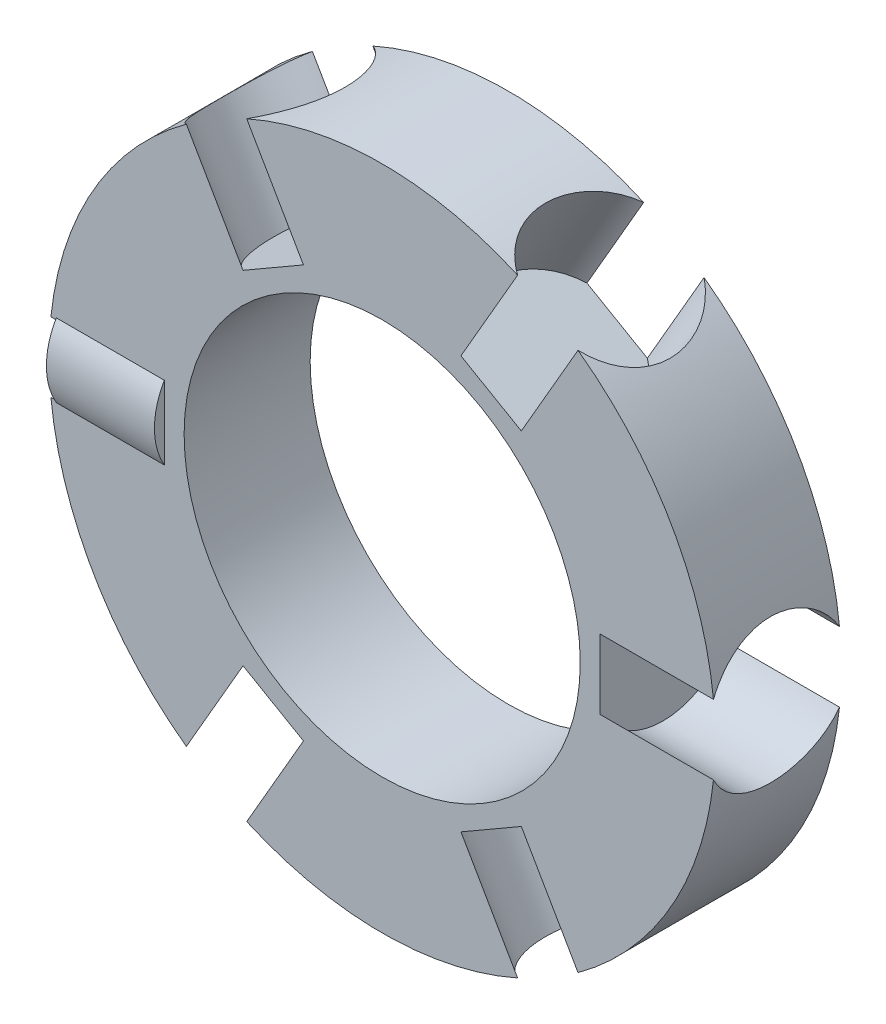
from build123d import *

# Parameters (mm, degrees)
SKETCH1_R           = 18.5
SKETCH1_R_2         = 11
BOSS_EXTRUDE1_DEPTH = 3.5
SKETCH2_R           = 4
CUT_EXTRUDE3_DEPTH  = 6.4
CIRPATTERN1_COUNT   = 6
SKETCH3_R           = 4.05
BOSS_EXTRUDE2_DEPTH = 6


with BuildPart() as part:
    # Sketch1 → Boss-Extrude1 (new, symmetric)
    with BuildSketch(Plane.XY):
        Circle(SKETCH1_R)
        Circle(SKETCH1_R_2, mode=Mode.SUBTRACT)
    extrude(amount=BOSS_EXTRUDE1_DEPTH, both=True)

    # Sketch2 → Cut-Extrude3 (cut)
    with BuildSketch(Plane(origin=(-18.5, -17.193061184, 0), x_dir=(0, -1, 0), z_dir=(1, 0, 0))):
        with Locations((-17.193061184, 0)):
            Circle(SKETCH2_R)
    cut_extrude3 = extrude(amount=CUT_EXTRUDE3_DEPTH, mode=Mode.SUBTRACT)

    # CirPattern1: Cut-Extrude3 ×6 about axis
    cirpattern1_axis = Axis((0, 0, 3.5), (0, 0, 1))
    for i in range(1, CIRPATTERN1_COUNT):
        add(cut_extrude3.rotate(cirpattern1_axis, i * 360 / CIRPATTERN1_COUNT), mode=Mode.SUBTRACT)

    # Sketch3 → Boss-Extrude2 (add)
    with BuildSketch(Plane(origin=(-12.1, 0, 0), x_dir=(0, -1, 0), z_dir=(-1, 0, 0))):
        Circle(SKETCH3_R)
    extrude(amount=BOSS_EXTRUDE2_DEPTH)


solid = part.part
